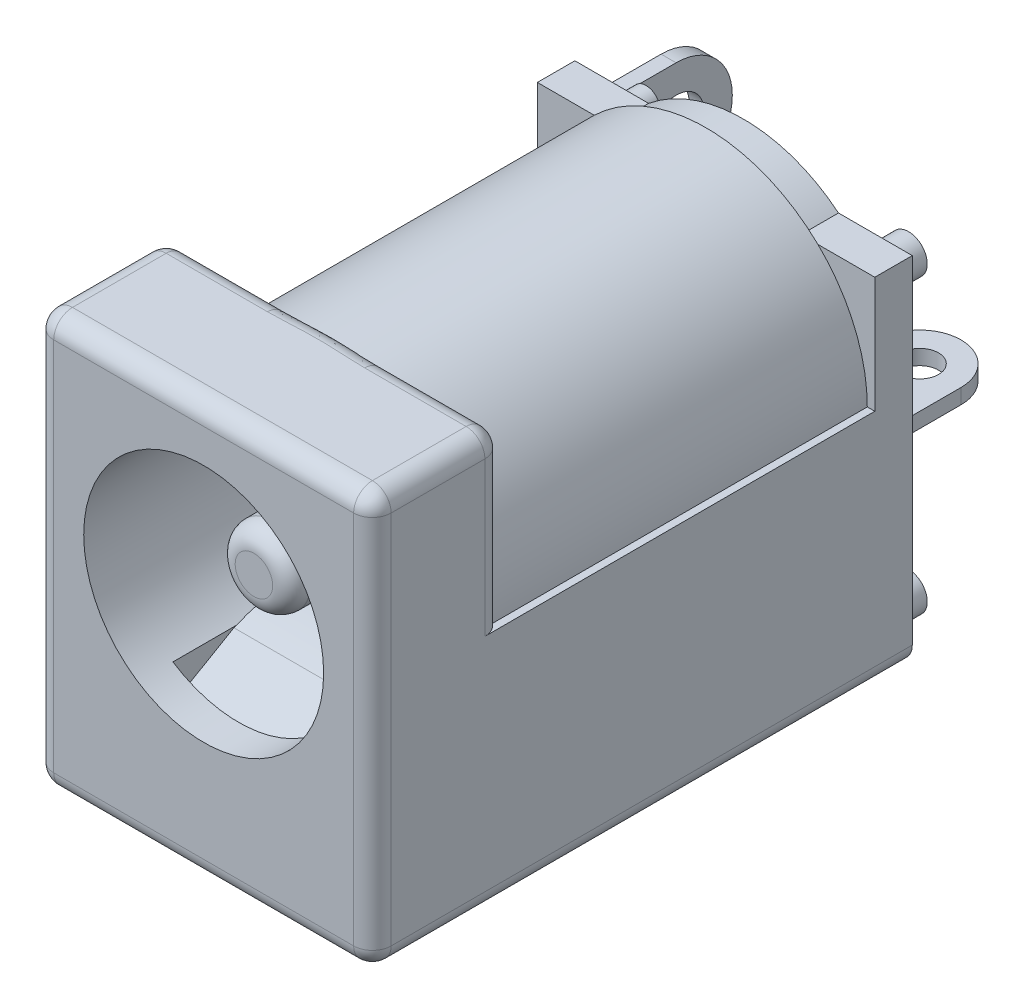
from build123d import *

# Parameters (mm, degrees)
SKETCH1_W           = 9
SKETCH1_H           = 11
BASE_EXTRUDE_DEPTH  = 3.5
BOSS_EXTRUDE1_DEPTH = 9.9
SKETCH3_R           = 3.2
CUT_EXTRUDE1_DEPTH  = 9.144
SKETCH4_R           = 1
EXTRUDE1_DEPTH      = 7.804
FILLET1_R           = 0.5
BOSS_EXTRUDE2_DEPTH = 1
SKETCH22_W          = 0.413257786
SKETCH22_H          = 0.581135983
BOSS_EXTRUDE3_DEPTH = 0.4
SKETCH23_R          = 0.5
SKETCH23_R_2        = 0.375
BOSS_EXTRUDE4_DEPTH = 0.9
SKETCH24_W          = 2.2
SKETCH24_H          = 0.4
SKETCH24_H_2        = 0.25
BOSS_EXTRUDE5_DEPTH = 4.4
SKETCH5_R           = 0.75
EXTRUDE2_DEPTH      = 0.2
SKETCH25_R          = 0.5
CUT_EXTRUDE5_DEPTH  = 12.2
SKETCH26_R          = 1.235253259
BOSS_EXTRUDE6_DEPTH = 0.3
FILLET2_R           = 0.5
SKETCH28_W          = 8.199907687
SKETCH28_H          = 3.89034232
CUT_EXTRUDE6_DEPTH  = 1.75
BOSS_EXTRUDE7_DEPTH = 1.5


with BuildPart() as part:
    # Sketch1 → Base-Extrude (new body)
    with BuildSketch(Plane.XY):
        with Locations((0, 5.5)):
            Rectangle(SKETCH1_W, SKETCH1_H)
    extrude(amount=-BASE_EXTRUDE_DEPTH)

    # Sketch2 → Boss-Extrude1 (add)
    with BuildSketch(Plane(origin=(0, 0, -3.5), x_dir=(-1, 0, 0), z_dir=(0, 0, -1))):
        with BuildLine():
            Line((-4.5, 0), (-4.5, 6.4))
            Line((-4.5, 6.4), (-4.3, 6.4))
            ThreePointArc((-4.3, 6.4), (0, 10.7), (4.3, 6.4))
            Line((4.3, 6.4), (4.5, 6.4))
            Line((4.5, 6.4), (4.5, 0))
            Line((4.5, 0), (-4.5, 0))
        make_face()
    extrude(amount=BOSS_EXTRUDE1_DEPTH)

    # Sketch3 → Cut-Extrude1 (cut)
    with BuildSketch(Plane.XY):
        with Locations((0, 6.4)):
            Circle(SKETCH3_R)
    extrude(amount=-CUT_EXTRUDE1_DEPTH, mode=Mode.SUBTRACT)

    # Sketch4 → Extrude1 (add)
    with BuildSketch(Plane.XY.offset(-9.144)):
        with Locations((0, 6.4)):
            Circle(SKETCH4_R)
    extrude(amount=EXTRUDE1_DEPTH)

    # Fillet1
    fillet1_edges = [part.edges().sort_by_distance(p)[0] for p in [
        (-1, 6.4, -1.34),
    ]]
    fillet(fillet1_edges, radius=FILLET1_R)

    # Sketch21 → Boss-Extrude2 (add)
    with BuildSketch(Plane(origin=(0, 0, -13.4), x_dir=(-1, 0, 0), z_dir=(0, 0, -1))):
        with BuildLine():
            Line((2.531952195, 9.496646264), (4.5, 9.496646264))
            Line((4.5, 9.496646264), (4.5, 6.4))
            Line((4.5, 6.4), (4.5, 0))
            Line((4.5, 0), (-4.5, 0))
            Line((-4.5, 0), (-4.5, 6.4))
            Line((-4.5, 6.4), (-4.5, 9.496646264))
            Line((-4.5, 9.496646264), (-2.531952195, 9.496646264))
            ThreePointArc((-2.531952195, 9.496646264), (0, 10.4), (2.531952195, 9.496646264))
        make_face()
    extrude(amount=BOSS_EXTRUDE2_DEPTH)

    # Sketch22 → Boss-Extrude3 (add)
    with BuildSketch(Plane(origin=(0, 0, -14.4), x_dir=(-1, 0, 0), z_dir=(0, 0, -1))):
        with BuildLine():
            Line((2.55496541, 7.9), (4.9, 7.9))
            Line((4.9, 7.9), (4.9, 4.9))
            Line((4.9, 4.9), (2.55496541, 4.9))
            Line((2.55496541, 4.9), (2.55496541, 4.366018911))
            Line((2.55496541, 4.366018911), (0, 4.366018911))
            ThreePointArc((0, 4.366018911), (-2.033981089, 6.4), (0, 8.433981089))
            Line((0, 8.433981089), (2.55496541, 8.433981089))
            Line((2.55496541, 8.433981089), (2.55496541, 7.9))
        make_face()
        with Locations((2.522410809, 6.417062755)):
            Rectangle(SKETCH22_W, SKETCH22_H, mode=Mode.SUBTRACT)
    extrude(amount=BOSS_EXTRUDE3_DEPTH)

    # Sketch23 → Boss-Extrude4 (add)
    with BuildSketch(Plane(origin=(0, 0, -14.4), x_dir=(-1, 0, 0), z_dir=(0, 0, -1))):
        with Locations((-3.5, 0.8)):
            Circle(SKETCH23_R)
        with Locations((3.5, 0.8)):
            Circle(SKETCH23_R)
        with Locations((-3.5, 8.6)):
            Circle(SKETCH23_R)
        with Locations((3.5, 8.6)):
            Circle(SKETCH23_R_2)
    extrude(amount=BOSS_EXTRUDE4_DEPTH)

    # Sketch24 → Boss-Extrude5 (add)
    with BuildSketch(Plane(origin=(0, 0, -14.4), x_dir=(-1, 0, 0), z_dir=(0, 0, -1))):
        with Locations((-1.4, 3.6)):
            Rectangle(SKETCH24_W, SKETCH24_H)
        with Locations((1.4, 0.8)):
            Rectangle(SKETCH24_W, SKETCH24_H_2)
    extrude(amount=BOSS_EXTRUDE5_DEPTH)

    # Sketch5 → Extrude2 (add, symmetric)
    with BuildSketch(Plane(origin=(-4.9, 0, 0), x_dir=(0, 0, -1), z_dir=(1, 0, 0))):
        with BuildLine():
            Line((14.4, 7.9), (17.3, 7.9))
            ThreePointArc((17.3, 7.9), (18.8, 6.4), (17.3, 4.9))
            Line((17.3, 4.9), (14.4, 4.9))
            Line((14.4, 4.9), (14.4, 7.9))
        make_face()
        with Locations((17.3, 6.4)):
            Circle(SKETCH5_R, mode=Mode.SUBTRACT)
    extrude(amount=EXTRUDE2_DEPTH, both=True)

    # Sketch25 → Cut-Extrude5 (cut)
    with BuildSketch(Plane(origin=(0, 3.8, 0), x_dir=(1, 0, 0), z_dir=(0, 1, 0))):
        with Locations((-1.4, 17.7)):
            Circle(SKETCH25_R)
        with Locations((1.4, 17.7)):
            Circle(SKETCH25_R)
        with BuildLine():
            Line((0.3, 17.7), (0.3, 18.8))
            Line((0.3, 18.8), (1.814838084, 19.127754717))
            Line((1.814838084, 19.127754717), (2.5, 18.8))
            Line((2.5, 18.8), (2.5, 17.7))
            ThreePointArc((2.5, 17.7), (1.4, 18.8), (0.3, 17.7))
        make_face()
        with BuildLine():
            Line((-2.5, 17.7), (-2.5, 18.8))
            Line((-2.5, 18.8), (-1.388936506, 19.127754717))
            Line((-1.388936506, 19.127754717), (-0.3, 18.8))
            Line((-0.3, 18.8), (-0.3, 17.7))
            ThreePointArc((-0.3, 17.7), (-1.4, 18.8), (-2.5, 17.7))
        make_face()
    extrude(amount=-CUT_EXTRUDE5_DEPTH, mode=Mode.SUBTRACT)

    # Sketch26 → Boss-Extrude6 (add)
    with BuildSketch(Plane(origin=(0, 0, -14.8), x_dir=(-1, 0, 0), z_dir=(0, 0, -1))):
        with Locations((0.197894438, 6.4)):
            Circle(SKETCH26_R)
    extrude(amount=BOSS_EXTRUDE6_DEPTH)

    # Fillet2
    fillet2_edges = [part.edges().sort_by_distance(p)[0] for p in [
        (0, 11, 0),
        (4.5, 5.5, 0),
        (0, 0, 0),
        (-4.5, 5.5, 0),
        (4.5, 8.7, -3.5),
        (4.5, 0, -7.2),
        (-4.5, 0, -7.2),
        (4.5, 11, -1.75),
        (0, 11, -3.5),
        (-4.5, 8.7, -3.5),
        (-4.5, 11, -1.75),
    ]]
    fillet(fillet2_edges, radius=FILLET2_R)

    # Sketch28 → Cut-Extrude6 (cut, symmetric)
    with BuildSketch(Plane(origin=(0, 0, 0), x_dir=(0, 0, -1), z_dir=(1, 0, 0))):
        with Locations((5.030081863, 3.009711686)):
            Rectangle(SKETCH28_W, SKETCH28_H)
    extrude(amount=CUT_EXTRUDE6_DEPTH, both=True, mode=Mode.SUBTRACT)

    # Sketch27 → Boss-Extrude7 (add, symmetric)
    with BuildSketch(Plane(origin=(0, 0, 0), x_dir=(0, 0, -1), z_dir=(1, 0, 0))):
        with BuildLine():
            Line((0.855128644, 3.105078739), (2.30673576, 3.9461551))
            ThreePointArc((2.30673576, 3.9461551), (4.216159937, 4.339068854), (6.125584114, 3.9461551))
            Line((6.125584114, 3.9461551), (9.059931405, 2.68512141))
            Line((9.059931405, 2.68512141), (8.9414814, 2.409495584))
            Line((8.9414814, 2.409495584), (6.007134108, 3.670529274))
            ThreePointArc((6.007134108, 3.670529274), (4.224971911, 4.039060295), (2.441391305, 3.677456327))
            Line((2.441391305, 3.677456327), (1.005529549, 2.845502993))
            Line((1.005529549, 2.845502993), (0.855128644, 3.105078739))
        make_face()
    extrude(amount=BOSS_EXTRUDE7_DEPTH, both=True)


solid = part.part
